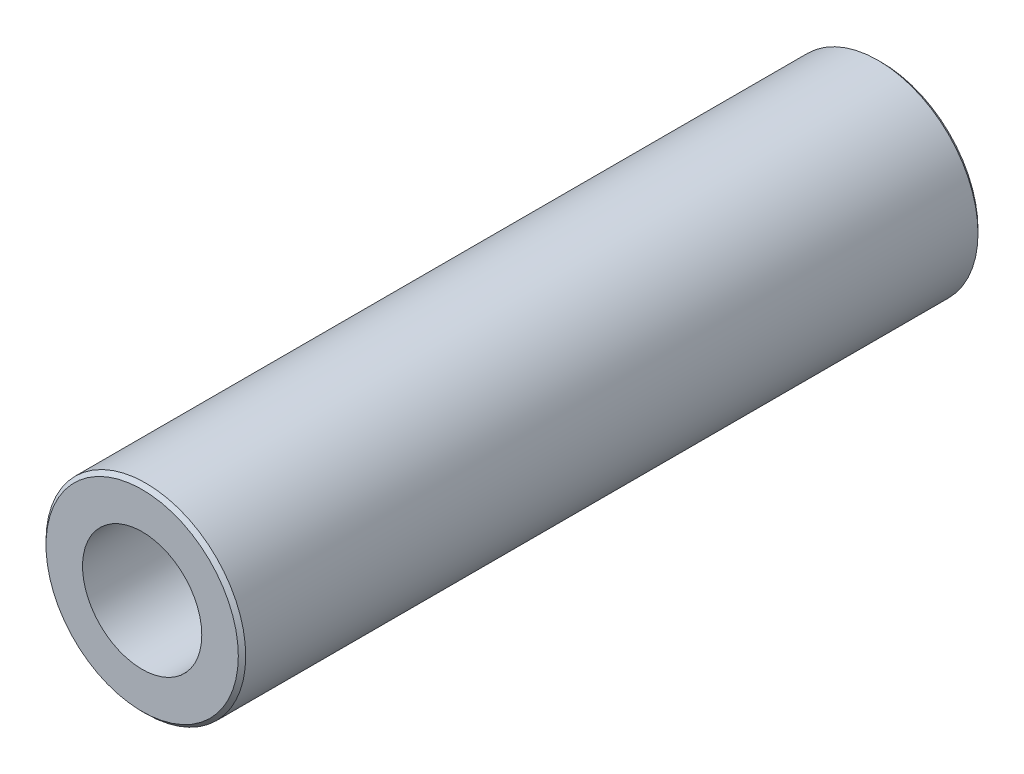
from build123d import *


with BuildPart() as part:
    # Sketch1 → Revolve1 (revolve)
    with BuildSketch(Plane(origin=(0, 0, 0), x_dir=(1, 0, 0), z_dir=(0, 1, 0))):
        Polygon((8.255, 0), (5.1181, 0), (5.1181, -63.5), (8.255, -63.5), (8.5725, -63.1825), (8.5725, -0.3175), align=None)
    revolve(axis=Axis((0, 0, 0), (0, 0, 1)))


solid = part.part
